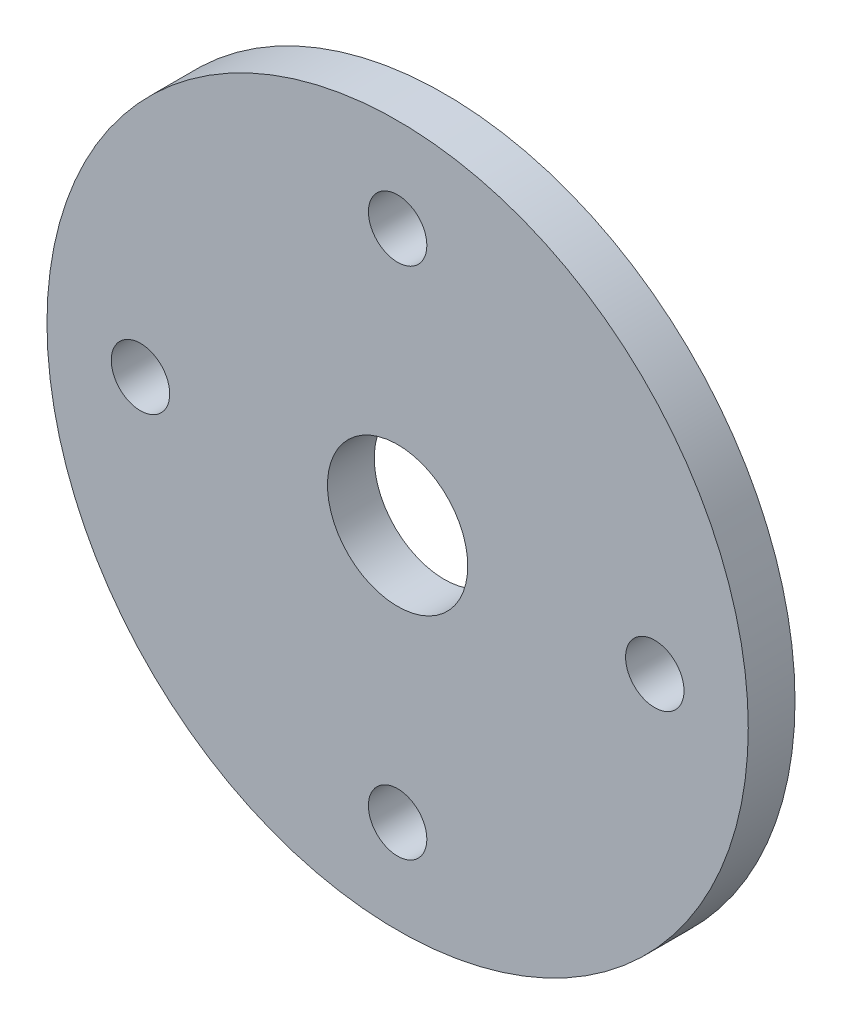
from build123d import *

# Parameters (mm, degrees)
ESQUISSE1_R        = 75
ESQUISSE1_R_2      = 15
ESQUISSE1_R_3      = 6.25
BOSS_EXTRU_1_DEPTH = 5


with BuildPart() as part:
    # Esquisse1 → Boss.-Extru.1 (new body, symmetric)
    with BuildSketch(Plane.XY):
        Circle(ESQUISSE1_R)
        Circle(ESQUISSE1_R_2, mode=Mode.SUBTRACT)
        with Locations((0, 55)):
            Circle(ESQUISSE1_R_3, mode=Mode.SUBTRACT)
        with Locations((-55, 0)):
            Circle(ESQUISSE1_R_3, mode=Mode.SUBTRACT)
        with Locations((0, -55)):
            Circle(ESQUISSE1_R_3, mode=Mode.SUBTRACT)
        with Locations((55, 0)):
            Circle(ESQUISSE1_R_3, mode=Mode.SUBTRACT)
    extrude(amount=BOSS_EXTRU_1_DEPTH, both=True)


solid = part.part
